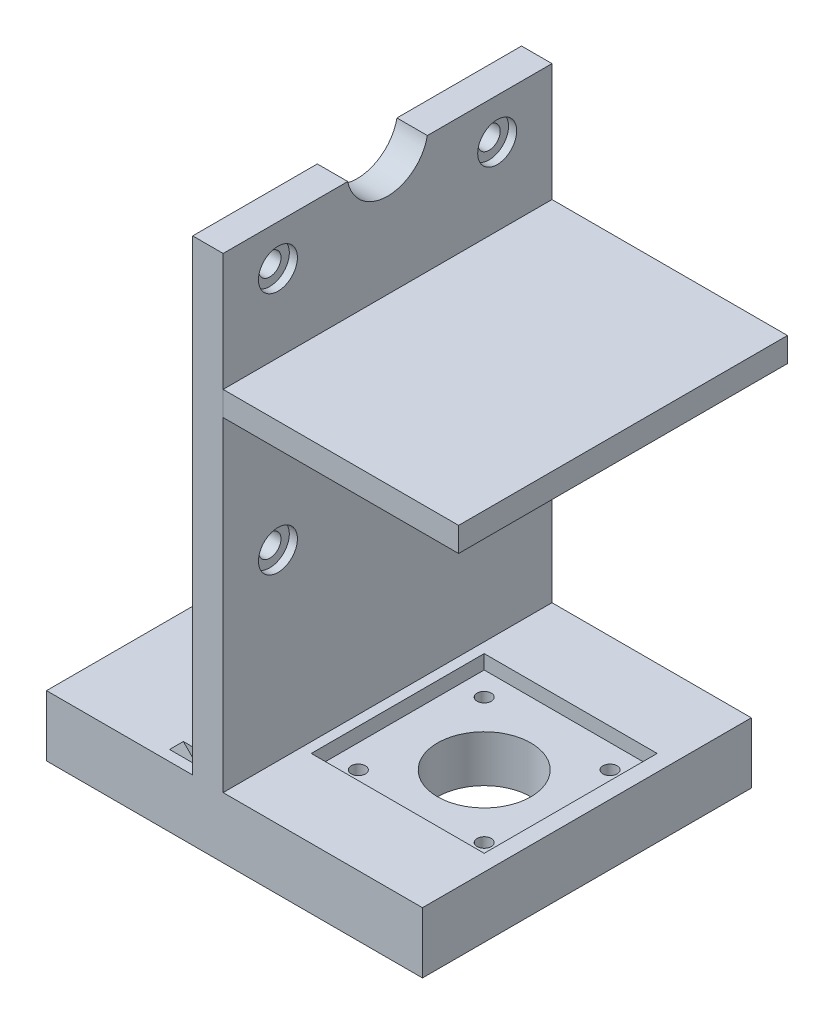
from build123d import *

# Parameters (mm, degrees)
SKETCH1_W               = 56.4
SKETCH1_H               = 67
SKETCH1_W_2             = 46.4
SKETCH1_H_2             = 55
BOSS_EXTRUDE1_DEPTH     = 14
SKETCH4_W               = 12
SKETCH4_H               = 12
BOSS_EXTRUDE2_DEPTH     = 200
SKETCH16_W              = 4.6
SKETCH16_H              = 14
BOSS_EXTRUDE11_DEPTH    = 43
SKETCH5_W               = 5
SKETCH5_H               = 67
BOSS_EXTRUDE3_DEPTH     = 14
BOSS_EXTRUDE4_REACH     = 216.011
SKETCH2_R               = 2.75
CUT_EXTRUDE1_DEPTH      = 5
SKETCH3_R               = 2.75
CUT_EXTRUDE2_DEPTH      = 210.198972273
SKETCH7_R               = 2.75
CUT_EXTRUDE3_DEPTH      = 217.851100989
SKETCH8_W               = 8
SKETCH8_H               = 14
BOSS_EXTRUDE5_DEPTH     = 1
SKETCH9_W               = 92.6
SKETCH9_H               = 81
SKETCH9_W_2             = 6.786539707
BOSS_EXTRUDE6_DEPTH     = 15
SKETCH10_W              = 42.6
SKETCH10_H              = 42.6
CUT_EXTRUDE4_DEPTH      = 3.5
SKETCH11_R              = 1.75
SKETCH11_R_2            = 11.5
CUT_EXTRUDE5_DEPTH      = 11.5
CUT_EXTRUDE6_START      = 8.5
SKETCH11_5_R            = 3
SKETCH11_5_R_2          = 1.75
SKETCH11_5_R_3          = 11.5
CUT_EXTRUDE6_DEPTH      = 3
SKETCH13_R              = 2.75
BOSS_EXTRUDE7_DEPTH     = 5.5
BOSS_EXTRUDE10_START    = -5.5
SKETCH13_3_R            = 4.8
BOSS_EXTRUDE10_DEPTH    = 2
SKETCH15_W              = 81
SKETCH15_H              = 6
BOSS_EXTRUDE9_DEPTH     = 58
SKETCH17_W              = 159.404685439
SKETCH17_H              = 222.014649432
CUT_EXTRUDE7_DEPTH      = 362.894321591
CUT_EXTRUDE7_DEPTH_BACK = 362.894321591
CUT_EXTRUDE8_DEPTH      = 45
BOSS_EXTRUDE13_DEPTH    = 6
CUT_EXTRUDE9_START      = -6
CUT_EXTRUDE9_DEPTH      = 3.4
CUT_EXTRUDE10_START     = -43.5
CUT_EXTRUDE10_DEPTH     = 3.4


with BuildPart() as part:
    # Sketch1 → Boss-Extrude1 (new body)
    with BuildSketch(Plane(origin=(0, 0, 0), x_dir=(1, 0, 0), z_dir=(0, 1, 0))):
        Rectangle(SKETCH1_W, SKETCH1_H)
        Rectangle(SKETCH1_W_2, SKETCH1_H_2, mode=Mode.SUBTRACT)
    extrude(amount=BOSS_EXTRUDE1_DEPTH)

    # Sketch4 → Boss-Extrude2 (add)
    with BuildSketch(Plane(origin=(0, 0, 0), x_dir=(1, 0, 0), z_dir=(0, 1, 0))):
        with Locations((-34.2, -27.5)):
            Rectangle(SKETCH4_W, SKETCH4_H)
        with Locations((-34.2, 27.5)):
            Rectangle(SKETCH4_W, SKETCH4_H)
    extrude(amount=BOSS_EXTRUDE2_DEPTH)

    # Sketch16 → Boss-Extrude11 (add)
    with BuildSketch(Plane.XY.offset(-21.5)):
        with Locations((-30.5, 7)):
            Rectangle(SKETCH16_W, SKETCH16_H)
    extrude(amount=BOSS_EXTRUDE11_DEPTH)

    # Sketch5 → Boss-Extrude3 (add)
    with BuildSketch(Plane(origin=(0, 200, 0), x_dir=(1, 0, 0), z_dir=(0, 1, 0))):
        with Locations((-25.7, 0)):
            Rectangle(SKETCH5_W, SKETCH5_H)
    extrude(amount=-BOSS_EXTRUDE3_DEPTH)

    # Boss-Extrude4: up to this face of the body (flat: up to its plane)
    boss_extrude4_end = Plane(part.part.faces().sort_by_distance((-28.2, 100, 27.5))[0])
    # Sketch6 → Boss-Extrude4 (add, up to the picked face)
    with BuildSketch(Plane.ZY.offset(40.2), mode=Mode.PRIVATE) as boss_extrude4_sk1:
        Polygon((21.5, 157.410301507), (-21.5, 186), (-21.5, 171.589698493), (21.5, 143), align=None)
    boss_extrude4_tool1 = split(extrude(boss_extrude4_sk1.sketch, amount=-BOSS_EXTRUDE4_REACH, mode=Mode.PRIVATE), bisect_by=boss_extrude4_end, keep=Keep.BOTH, mode=Mode.PRIVATE)
    # Sketch6 → Boss-Extrude4 (add, up to the picked face)
    with BuildSketch(Plane.ZY.offset(40.2), mode=Mode.PRIVATE) as boss_extrude4_sk2:
        Polygon((21.5, 128.589698493), (21.5, 143), (-21.5, 114.410301507), (-21.5, 100), align=None)
    boss_extrude4_tool2 = split(extrude(boss_extrude4_sk2.sketch, amount=-BOSS_EXTRUDE4_REACH, mode=Mode.PRIVATE), bisect_by=boss_extrude4_end, keep=Keep.BOTH, mode=Mode.PRIVATE)
    # Sketch6 → Boss-Extrude4 (add, up to the picked face)
    with BuildSketch(Plane.ZY.offset(40.2), mode=Mode.PRIVATE) as boss_extrude4_sk3:
        Polygon((21.5, 71.410301507), (-21.5, 100), (-21.5, 85.589698493), (21.5, 57), align=None)
    boss_extrude4_tool3 = split(extrude(boss_extrude4_sk3.sketch, amount=-BOSS_EXTRUDE4_REACH, mode=Mode.PRIVATE), bisect_by=boss_extrude4_end, keep=Keep.BOTH, mode=Mode.PRIVATE)
    # Sketch6 → Boss-Extrude4 (add, up to the picked face)
    with BuildSketch(Plane.ZY.offset(40.2), mode=Mode.PRIVATE) as boss_extrude4_sk4:
        Polygon((21.5, 42.589698493), (21.5, 57), (-21.5, 28.410301507), (-21.5, 14), align=None)
    boss_extrude4_tool4 = split(extrude(boss_extrude4_sk4.sketch, amount=-BOSS_EXTRUDE4_REACH, mode=Mode.PRIVATE), bisect_by=boss_extrude4_end, keep=Keep.BOTH, mode=Mode.PRIVATE)
    add(boss_extrude4_tool1.solids().sort_by(Axis((-40.2, 164.5, 0), (1, 0, 0)))[0])
    add(boss_extrude4_tool2.solids().sort_by(Axis((-40.2, 121.5, 0), (1, 0, 0)))[0])
    add(boss_extrude4_tool3.solids().sort_by(Axis((-40.2, 78.5, 0), (1, 0, 0)))[0])
    add(boss_extrude4_tool4.solids().sort_by(Axis((-40.2, 35.5, 0), (1, 0, 0)))[0])

    # Sketch2 → Cut-Extrude1 (cut)
    with BuildSketch(Plane(origin=(28.2, 0, 0), x_dir=(0, 0, -1), z_dir=(1, 0, 0))):
        with Locations((-20.75, 7)):
            Circle(SKETCH2_R)
        with Locations((20.75, 7)):
            Circle(SKETCH2_R)
    extrude(amount=-CUT_EXTRUDE1_DEPTH, mode=Mode.SUBTRACT)

    # Sketch3 → Cut-Extrude2 (cut, through all)
    with BuildSketch(Plane(origin=(-23.2, 0, 0), x_dir=(0, 0, -1), z_dir=(1, 0, 0))):
        with Locations((15.85, 7)):
            Circle(SKETCH3_R)
        with Locations((-15.85, 7)):
            Circle(SKETCH3_R)
    extrude(amount=-CUT_EXTRUDE2_DEPTH, mode=Mode.SUBTRACT)

    # Sketch7 → Cut-Extrude3 (cut, through all)
    with BuildSketch(Plane(origin=(-23.2, 0, -32.7), x_dir=(0, 0, -1), z_dir=(1, 0, 0))):
        with Locations((-16.85, 193)):
            Circle(SKETCH7_R)
        with Locations((-48.55, 193)):
            Circle(SKETCH7_R)
    extrude(amount=-CUT_EXTRUDE3_DEPTH, mode=Mode.SUBTRACT)

    # Sketch8 → Boss-Extrude5 (add)
    with BuildSketch(Plane(origin=(-23.2, 0, 0), x_dir=(0, 0, -1), z_dir=(1, 0, 0))):
        with Locations((-29.5, 193)):
            Rectangle(SKETCH8_W, SKETCH8_H)
        with Locations((29.5, 193)):
            Rectangle(SKETCH8_W, SKETCH8_H)
    extrude(amount=BOSS_EXTRUDE5_DEPTH)

    # Sketch17 → Cut-Extrude7 (cut, two sides)
    with BuildSketch(Plane.ZY.offset(24.2)) as cut_extrude7_sk:
        with Locations((0.680677332, 96.663888991)):
            Rectangle(SKETCH17_W, SKETCH17_H)
    extrude(amount=CUT_EXTRUDE7_DEPTH, mode=Mode.SUBTRACT)
    extrude(cut_extrude7_sk.sketch, amount=-CUT_EXTRUDE7_DEPTH_BACK, mode=Mode.SUBTRACT)


with BuildPart() as body_2:
    # Sketch9 → Boss-Extrude6 (new body)
    with BuildSketch(Plane(origin=(0, 215, 0), x_dir=(1, 0, 0), z_dir=(0, 1, 0))):
        with Locations((22.1, 0)):
            Rectangle(SKETCH9_W, SKETCH9_H)
        with Locations((-18.806730147, 0)):
            Rectangle(SKETCH9_W_2, SKETCH9_H)
    extrude(amount=BOSS_EXTRUDE6_DEPTH)

    # Sketch10 → Cut-Extrude4 (cut)
    with BuildSketch(Plane(origin=(0, 230, 0), x_dir=(1, 0, 0), z_dir=(0, 1, 0))):
        with Locations((43.1, 0)):
            Rectangle(SKETCH10_W, SKETCH10_H)
    extrude(amount=-CUT_EXTRUDE4_DEPTH, mode=Mode.SUBTRACT)

    # Sketch11 → Cut-Extrude5 (cut)
    with BuildSketch(Plane(origin=(0, 226.5, -221.5), x_dir=(1, 0, 0), z_dir=(0, -1, 0))):
        with Locations(Location((58.6, 237, 0), (0, 0, 90))):
            Circle(SKETCH11_R)
        with Locations(Location((27.6, 237, 0), (0, 0, 90))):
            Circle(SKETCH11_R)
        with Locations(Location((27.6, 206, 0), (0, 0, 90))):
            Circle(SKETCH11_R)
        with Locations(Location((58.6, 206, 0), (0, 0, 90))):
            Circle(SKETCH11_R)
        with Locations(Location((43.1, 221.5, 0), (0, 0, 90))):
            Circle(SKETCH11_R_2)
    extrude(amount=CUT_EXTRUDE5_DEPTH, mode=Mode.SUBTRACT)

    # Sketch11_5 → Cut-Extrude6 (cut)
    with BuildSketch(Plane(origin=(0, 226.5, -221.5), x_dir=(1, 0, 0), z_dir=(0, -1, 0)).offset(CUT_EXTRUDE6_START)):
        with Locations(Location((27.6, 237, 0), (0, 0, 90))):
            Circle(SKETCH11_5_R)
        with Locations(Location((27.6, 237, 0), (0, 0, 90))):
            Circle(SKETCH11_5_R_2, mode=Mode.SUBTRACT)
        with Locations(Location((58.6, 237, 0), (0, 0, 90))):
            Circle(SKETCH11_5_R)
        with Locations(Location((58.6, 237, 0), (0, 0, 90))):
            Circle(SKETCH11_5_R_2, mode=Mode.SUBTRACT)
        with Locations(Location((58.6, 206, 0), (0, 0, 90))):
            Circle(SKETCH11_5_R)
        with Locations(Location((58.6, 206, 0), (0, 0, 90))):
            Circle(SKETCH11_5_R_2, mode=Mode.SUBTRACT)
        with Locations(Location((27.6, 206, 0), (0, 0, 90))):
            Circle(SKETCH11_5_R)
        with Locations(Location((27.6, 206, 0), (0, 0, 90))):
            Circle(SKETCH11_5_R_2, mode=Mode.SUBTRACT)
        with Locations(Location((43.1, 221.5, 0), (0, 0, 90))):
            Circle(SKETCH11_5_R_3)
    extrude(amount=CUT_EXTRUDE6_DEPTH, mode=Mode.SUBTRACT)

    # Sketch18 → Cut-Extrude8 (cut)
    with BuildSketch(Plane.ZY.offset(24.2)):
        Polygon((-18.519847466, 225.2), (-33.5, 225.2), (-33.5, 219.7), (-25.5, 219.7), (-25.5, 215), (-6.363960821, 215), align=None)
        Polygon((14.963960821, 219.7), (14.963960821, 215), (34.1, 215), (21.944113356, 225.2), (6.963960821, 225.2), (6.963960821, 219.7), align=None)
    extrude(amount=-CUT_EXTRUDE8_DEPTH, mode=Mode.SUBTRACT)



with BuildPart() as body_3:
    # Sketch13 → Boss-Extrude7 (new body)
    with BuildSketch(Plane.ZY.offset(-11.8)):
        with BuildLine():
            Line((-9.806532844, 345), (-40.5, 345))
            Line((-40.5, 345), (-40.5, 230))
            Line((-40.5, 230), (40.5, 230))
            Line((40.5, 230), (40.5, 345))
            Line((40.5, 345), (9.806532844, 345))
            ThreePointArc((9.806532844, 345), (0, 336.957527416), (-9.806532844, 345))
        make_face()
        with Locations((-27, 275)):
            Circle(SKETCH13_R, mode=Mode.SUBTRACT)
        with Locations((27, 335)):
            Circle(SKETCH13_R, mode=Mode.SUBTRACT)
        with Locations((27, 275)):
            Circle(SKETCH13_R, mode=Mode.SUBTRACT)
        with Locations((-27, 335)):
            Circle(SKETCH13_R, mode=Mode.SUBTRACT)
    extrude(amount=-BOSS_EXTRUDE7_DEPTH)

    # Sketch13_3 → Boss-Extrude10 (add)
    with BuildSketch(Plane.ZY.offset(-11.8).offset(BOSS_EXTRUDE10_START)):
        with BuildLine():
            Line((-9.806532844, 345), (-40.5, 345))
            Line((-40.5, 345), (-40.5, 230))
            Line((-40.5, 230), (40.5, 230))
            Line((40.5, 230), (40.5, 345))
            Line((40.5, 345), (9.806532844, 345))
            ThreePointArc((9.806532844, 345), (0, 336.957527416), (-9.806532844, 345))
        make_face()
        with Locations((-27, 275)):
            Circle(SKETCH13_3_R, mode=Mode.SUBTRACT)
        with Locations((27, 275)):
            Circle(SKETCH13_3_R, mode=Mode.SUBTRACT)
        with Locations((-27, 335)):
            Circle(SKETCH13_3_R, mode=Mode.SUBTRACT)
        with Locations((27, 335)):
            Circle(SKETCH13_3_R, mode=Mode.SUBTRACT)
    extrude(amount=-BOSS_EXTRUDE10_DEPTH)


with BuildPart() as body_4:
    # Sketch15 → Boss-Extrude9 (new body)
    with BuildSketch(Plane(origin=(19.3, 0, 0), x_dir=(0, 0, -1), z_dir=(1, 0, 0))):
        with Locations((0, 313)):
            Rectangle(SKETCH15_W, SKETCH15_H)
    extrude(amount=BOSS_EXTRUDE9_DEPTH)


with BuildPart() as body_2_1:
    add(body_2.part)

    add(body_3.part)  # Boss-Extrude13 merges body 3
    # Sketch19 → Boss-Extrude13 (add)
    with BuildSketch(Plane(origin=(0, 0, -40.5), x_dir=(-1, 0, 0), z_dir=(0, 0, -1))):
        Polygon((-11.8, 265), (23.2, 230), (-11.8, 230), align=None)
    extrude(amount=-BOSS_EXTRUDE13_DEPTH)

    # Sketch21 → Cut-Extrude9 (cut)
    with BuildSketch(Plane.XY.offset(40.5).offset(CUT_EXTRUDE9_START)):
        Polygon((11.8, 238.3), (16.1, 234), (16.1, 225.7), (7.8, 225.7), (3.5, 230), (11.8, 230), align=None)
    extrude(amount=CUT_EXTRUDE9_DEPTH, mode=Mode.SUBTRACT)

    # Sketch21_2 → Cut-Extrude10 (cut)
    with BuildSketch(Plane.XY.offset(40.5).offset(CUT_EXTRUDE10_START)):
        Polygon((11.8, 238.3), (16.1, 234), (16.1, 225.7), (7.8, 225.7), (3.5, 230), (11.8, 230), align=None)
    extrude(amount=CUT_EXTRUDE10_DEPTH, mode=Mode.SUBTRACT)


solid = Compound([body_4.part, body_2_1.part])
